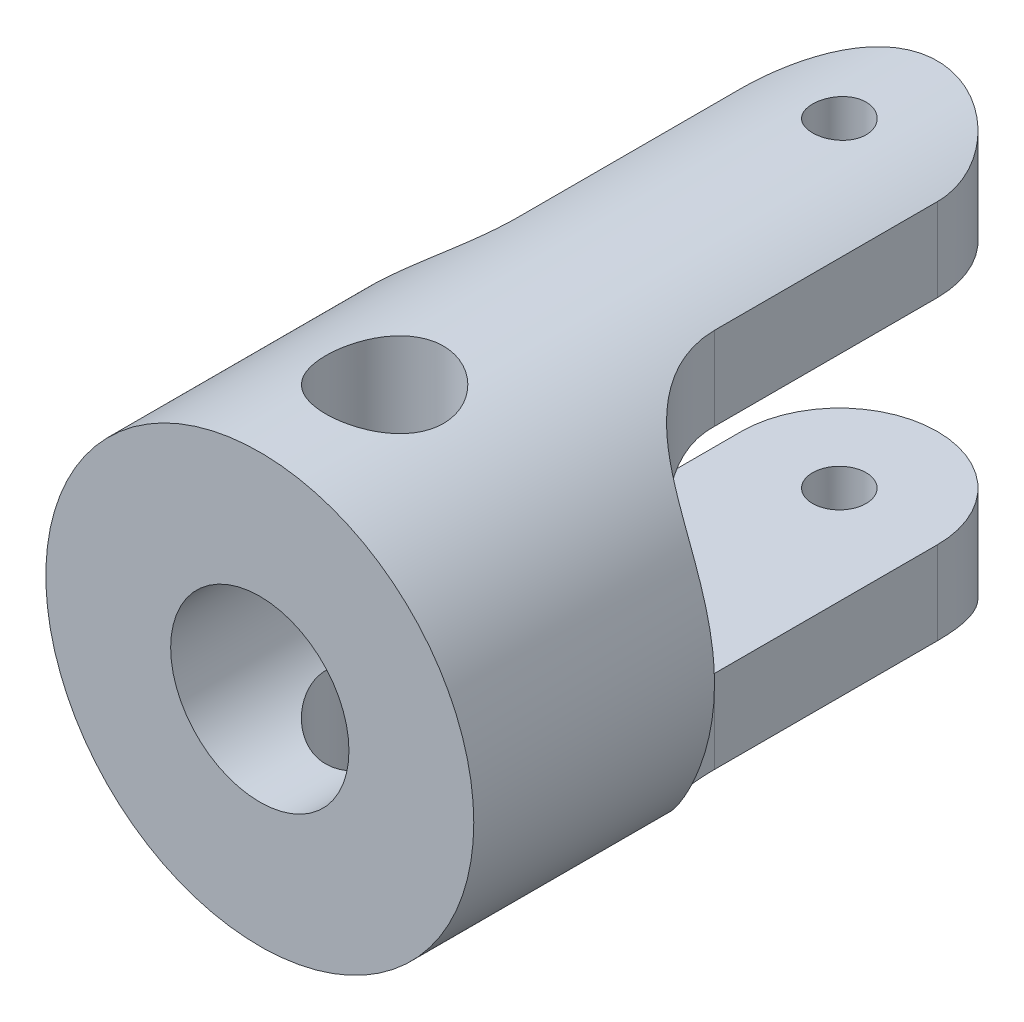
from build123d import *

# Parameters (mm, degrees)
SKETCH_1_R             = 6
SKETCH_1_R_2           = 2.5
EXTRUDE_1_DEPTH        = 19
SKETCH_2_OUTSIDE_W     = 19.096
SKETCH_2_OUTSIDE_H     = 26.096
SKETCH_2_OUTSIDE_R     = 0.75
CUT_EXTRUDE_1_DEPTH    = 9.5
CUT_EXTRUDE_2_DEPTH    = 9.5
HOLE_WIZARD_M4_1_D     = 3.3
HOLE_WIZARD_M4_1_DEPTH = 20
HOLE_WIZARD_M4_1_TIP   = 0.991420021


with BuildPart() as part:
    # 草图1 → 凸台-拉伸1 (new body)
    with BuildSketch(Plane.XY):
        Circle(SKETCH_1_R)
        Circle(SKETCH_1_R_2, mode=Mode.SUBTRACT)
    extrude(amount=EXTRUDE_1_DEPTH)

    # 草图2 outside → 切除-拉伸1 (cut, symmetric)
    with BuildSketch(Plane(origin=(0, 0, 0), x_dir=(1, 0, 0), z_dir=(0, 1, 0))):
        with Locations((0, -9.5)):
            Rectangle(SKETCH_2_OUTSIDE_W, SKETCH_2_OUTSIDE_H)
        with BuildLine():
            Line((-2.75, -2.75), (-2.75, -9))
            ThreePointArc((-2.75, -9), (-3.701902961, -11.298097039), (-6, -12.25))
            Line((-6, -12.25), (-6, -19))
            Line((-6, -19), (6, -19))
            Line((6, -19), (6, -12.25))
            ThreePointArc((6, -12.25), (3.701902961, -11.298097039), (2.75, -9))
            Line((2.75, -9), (2.75, -2.75))
            ThreePointArc((2.75, -2.75), (0, 0), (-2.75, -2.75))
        make_face(mode=Mode.SUBTRACT)
        with Locations((0, -2.75)):
            Circle(SKETCH_2_OUTSIDE_R)
    extrude(amount=CUT_EXTRUDE_1_DEPTH, both=True, mode=Mode.SUBTRACT)

    # 草图3 → 切除-拉伸2 (cut, symmetric)
    with BuildSketch(Plane(origin=(0, 0, 0), x_dir=(0, 0, -1), z_dir=(1, 0, 0))):
        with BuildLine():
            Line((-9.250000001, 3), (0, 3))
            Line((0, 3), (0, -3))
            Line((0, -3), (-9.250000001, -3))
            ThreePointArc((-9.250000001, -3), (-12.250000001, 0), (-9.250000001, 3))
        make_face()
    extrude(amount=CUT_EXTRUDE_2_DEPTH, both=True, mode=Mode.SUBTRACT)

    # M4 螺纹孔1
    with Locations(Plane(origin=(0, 6, 0), x_dir=(1, 0, 0), z_dir=(0, 1, 0))):
        with Locations((0, -15.5)):
            Hole(HOLE_WIZARD_M4_1_D / 2, depth=HOLE_WIZARD_M4_1_DEPTH)
            with Locations((0, 0, -(HOLE_WIZARD_M4_1_DEPTH + HOLE_WIZARD_M4_1_TIP / 2))):  # 118° drill point
                Cone(0, HOLE_WIZARD_M4_1_D / 2, HOLE_WIZARD_M4_1_TIP, mode=Mode.SUBTRACT)


solid = part.part
